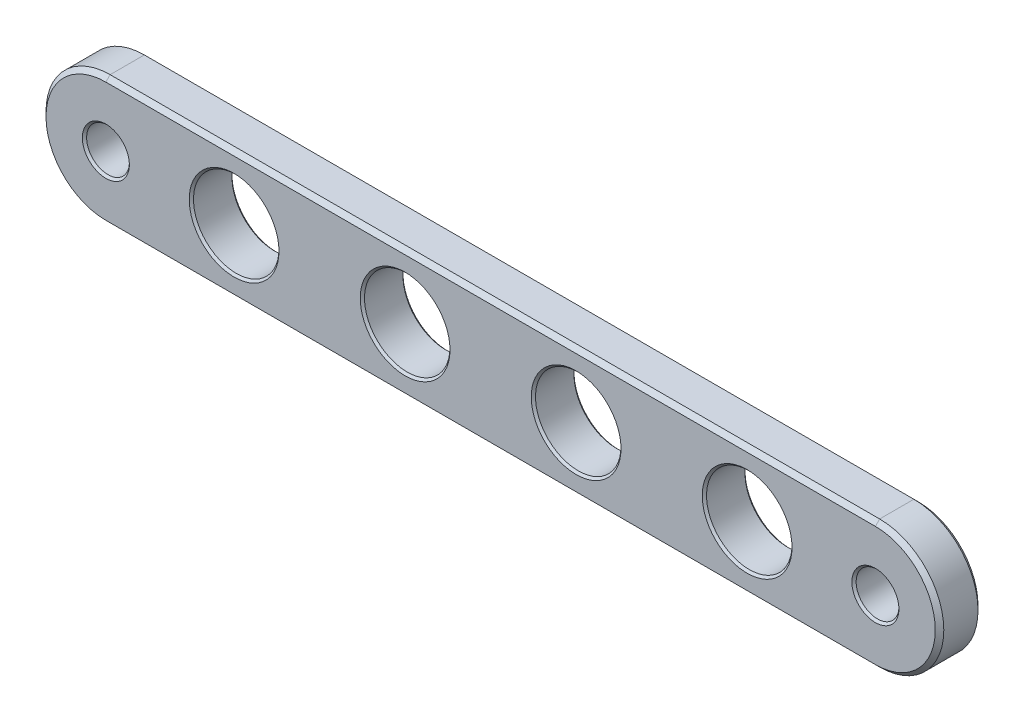
from build123d import *

# Parameters (mm, degrees)
BOSS_EXTRUDE1_DEPTH = 2
CHAMFER3_SIZE       = 0.2
SKETCH4_R           = 1
SKETCH4_R_2         = 2
CUT_EXTRUDE3_DEPTH  = 2
CHAMFER5_SIZE       = 0.1
CHAMFER6_SIZE       = 0.1


with BuildPart() as part:
    # Sketch1 → Boss-Extrude1 (new body)
    with BuildSketch(Plane.XY):
        with BuildLine():
            Line((-18, 3), (18, 3))
            ThreePointArc((18, 3), (21, 0), (18, -3))
            Line((18, -3), (-18, -3))
            ThreePointArc((-18, -3), (-21, 0), (-18, 3))
        make_face()
    extrude(amount=BOSS_EXTRUDE1_DEPTH)

    # Chamfer3
    chamfer3_edges = [part.edges().sort_by_distance(p)[0] for p in [
        (21, 0, 2),
        (0, 3, 2),
        (-21, 0, 2),
        (0, 3, 0),
        (21, 0, 0),
        (0, -3, 0),
        (-21, 0, 0),
        (0, -3, 2),
    ]]
    chamfer(chamfer3_edges, length=CHAMFER3_SIZE)

    # Sketch4 → Cut-Extrude3 (cut)
    with BuildSketch(Plane.XY.offset(2)):
        with Locations((-18, 0)):
            Circle(SKETCH4_R)
        with Locations((-12, 0)):
            Circle(SKETCH4_R_2)
        with Locations((-4, 0)):
            Circle(SKETCH4_R_2)
        with Locations((4, 0)):
            Circle(SKETCH4_R_2)
        with Locations((12, 0)):
            Circle(SKETCH4_R_2)
        with Locations((18, 0)):
            Circle(SKETCH4_R)
    extrude(amount=-CUT_EXTRUDE3_DEPTH, mode=Mode.SUBTRACT)

    # Chamfer5
    chamfer5_edges = [part.edges().sort_by_distance(p)[0] for p in [
        (-19, 0, 2),
        (-6, 0, 2),
        (-14, 0, 2),
        (2, 0, 2),
        (10, 0, 2),
        (17, 0, 2),
    ]]
    chamfer(chamfer5_edges, length=CHAMFER5_SIZE)

    # Chamfer6
    chamfer6_edges = [part.edges().sort_by_distance(p)[0] for p in [
        (-19, 0, 0),
        (-6, 0, 0),
        (-14, 0, 0),
        (2, 0, 0),
        (10, 0, 0),
        (17, 0, 0),
    ]]
    chamfer(chamfer6_edges, length=CHAMFER6_SIZE)


solid = part.part
